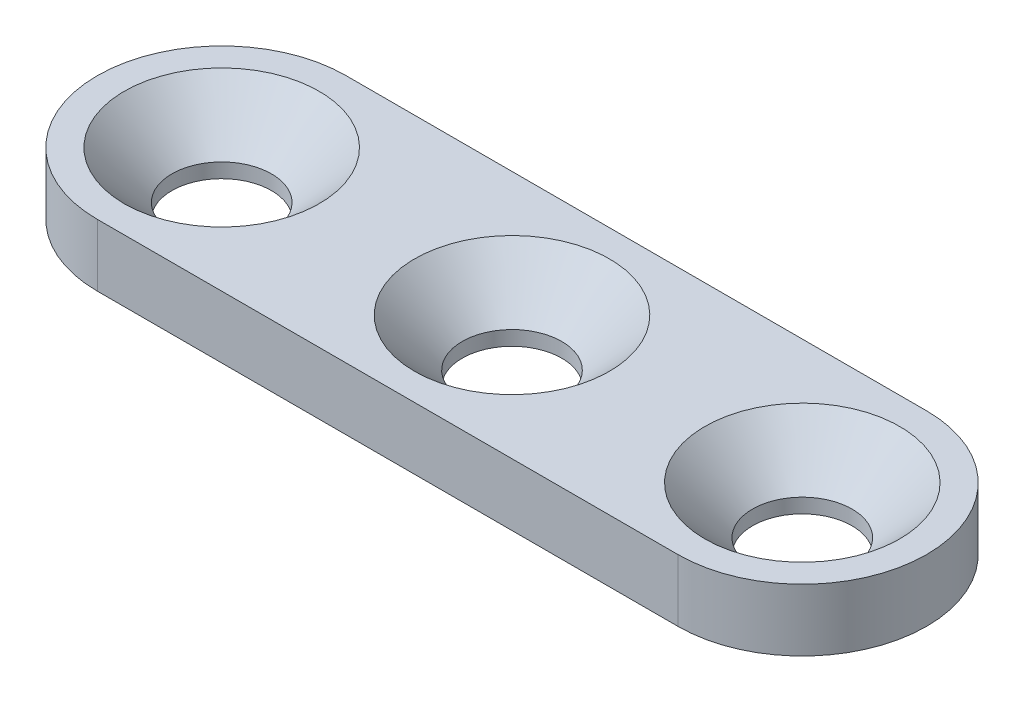
from build123d import *

# Parameters (mm, degrees)
SKETCH1_R                                       = 2
BOSS_EXTRUDE2_DEPTH                             = 3
CSK_FOR_M4_FLAT_HEAD_MACHINE_SCREW1_D           = 4.8
CSK_FOR_M4_FLAT_HEAD_MACHINE_SCREW1_DEPTH       = 22.23
CSK_FOR_M4_FLAT_HEAD_MACHINE_SCREW1_CSINK_D     = 9.4
CSK_FOR_M4_FLAT_HEAD_MACHINE_SCREW1_CSINK_ANGLE = 90
CSK_FOR_M4_FLAT_HEAD_MACHINE_SCREW1_TIP         = 1.442065486
CSK_FOR_M4_FLAT_HEAD_MACHINE_SCREW2_D           = 4.8
CSK_FOR_M4_FLAT_HEAD_MACHINE_SCREW2_DEPTH       = 22.23
CSK_FOR_M4_FLAT_HEAD_MACHINE_SCREW2_CSINK_D     = 9.4
CSK_FOR_M4_FLAT_HEAD_MACHINE_SCREW2_CSINK_ANGLE = 90
CSK_FOR_M4_FLAT_HEAD_MACHINE_SCREW2_TIP         = 1.442065486


with BuildPart() as part:
    # Sketch1 → Boss-Extrude2 (new body)
    with BuildSketch(Plane(origin=(0, 0, 0), x_dir=(1, 0, 0), z_dir=(0, 1, 0))):
        with BuildLine():
            Line((-28, 6), (0, 6))
            ThreePointArc((0, 6), (6, 0), (0, -6))
            Line((0, -6), (-28, -6))
            ThreePointArc((-28, -6), (-34, 0), (-28, 6))
        make_face()
        with Locations((-28, 0)):
            Circle(SKETCH1_R, mode=Mode.SUBTRACT)
        with Locations((-14, 0)):
            Circle(SKETCH1_R, mode=Mode.SUBTRACT)
        Circle(SKETCH1_R, mode=Mode.SUBTRACT)
    extrude(amount=BOSS_EXTRUDE2_DEPTH)

    # CSK for M4 Flat Head Machine Screw1
    with Locations(Plane(origin=(0, 3, 0), x_dir=(1, 0, 0), z_dir=(0, 1, 0))):
        with Locations((-14, 0)):
            CounterSinkHole(CSK_FOR_M4_FLAT_HEAD_MACHINE_SCREW1_D / 2, CSK_FOR_M4_FLAT_HEAD_MACHINE_SCREW1_CSINK_D / 2, depth=CSK_FOR_M4_FLAT_HEAD_MACHINE_SCREW1_DEPTH, counter_sink_angle=CSK_FOR_M4_FLAT_HEAD_MACHINE_SCREW1_CSINK_ANGLE)
            with Locations((0, 0, -(CSK_FOR_M4_FLAT_HEAD_MACHINE_SCREW1_DEPTH + CSK_FOR_M4_FLAT_HEAD_MACHINE_SCREW1_TIP / 2))):  # 118° drill point
                Cone(0, CSK_FOR_M4_FLAT_HEAD_MACHINE_SCREW1_D / 2, CSK_FOR_M4_FLAT_HEAD_MACHINE_SCREW1_TIP, mode=Mode.SUBTRACT)

    # CSK for M4 Flat Head Machine Screw2
    with Locations(Plane(origin=(0, 3, 0), x_dir=(1, 0, 0), z_dir=(0, 1, 0))):
        with Locations((-28, 0), (0, 0)):
            CounterSinkHole(CSK_FOR_M4_FLAT_HEAD_MACHINE_SCREW2_D / 2, CSK_FOR_M4_FLAT_HEAD_MACHINE_SCREW2_CSINK_D / 2, depth=CSK_FOR_M4_FLAT_HEAD_MACHINE_SCREW2_DEPTH, counter_sink_angle=CSK_FOR_M4_FLAT_HEAD_MACHINE_SCREW2_CSINK_ANGLE)
            with Locations((0, 0, -(CSK_FOR_M4_FLAT_HEAD_MACHINE_SCREW2_DEPTH + CSK_FOR_M4_FLAT_HEAD_MACHINE_SCREW2_TIP / 2))):  # 118° drill point
                Cone(0, CSK_FOR_M4_FLAT_HEAD_MACHINE_SCREW2_D / 2, CSK_FOR_M4_FLAT_HEAD_MACHINE_SCREW2_TIP, mode=Mode.SUBTRACT)


solid = part.part
